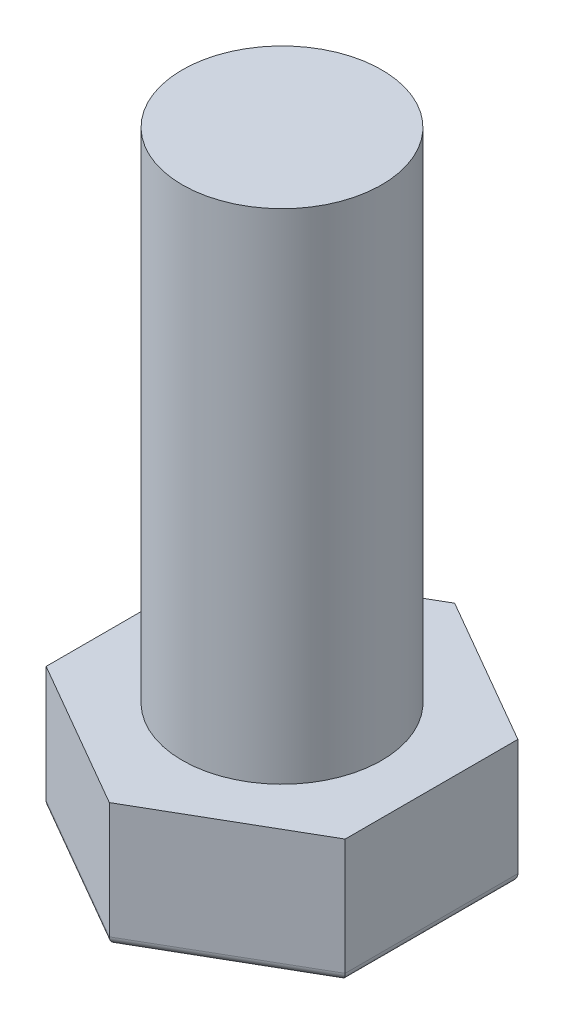
from build123d import *

# Parameters (mm, degrees)
EXTRUDE_1_DEPTH = 15
SKETCH_2_R      = 12
EXTRUDE_2_DEPTH = 60
FILLET_1_R      = 1


with BuildPart() as part:
    # 草圖1 → 填料-伸長1 (new body)
    with BuildSketch(Plane(origin=(0, 0, 0), x_dir=(1, 0, 0), z_dir=(0, 1, 0))):
        Polygon((18, -10.392304845), (18, 10.392304845), (0, 20.784609691), (-18, 10.392304845), (-18, -10.392304845), (0, -20.784609691), align=None)
    extrude(amount=EXTRUDE_1_DEPTH)

    # 草圖2 → 填料-伸長2 (add)
    with BuildSketch(Plane(origin=(0, 15, 0), x_dir=(1, 0, 0), z_dir=(0, 1, 0))):
        Circle(SKETCH_2_R)
    extrude(amount=EXTRUDE_2_DEPTH)

    # 圓角1
    fillet_1_edges = [part.edges().sort_by_distance(p)[0] for p in [
        (18, 0, 0),
        (9, 0, 15.588457268),
        (-9, 0, 15.588457268),
        (-18, 0, 0),
        (-9, 0, -15.588457268),
        (9, 0, -15.588457268),
    ]]
    fillet(fillet_1_edges, radius=FILLET_1_R)


solid = part.part
